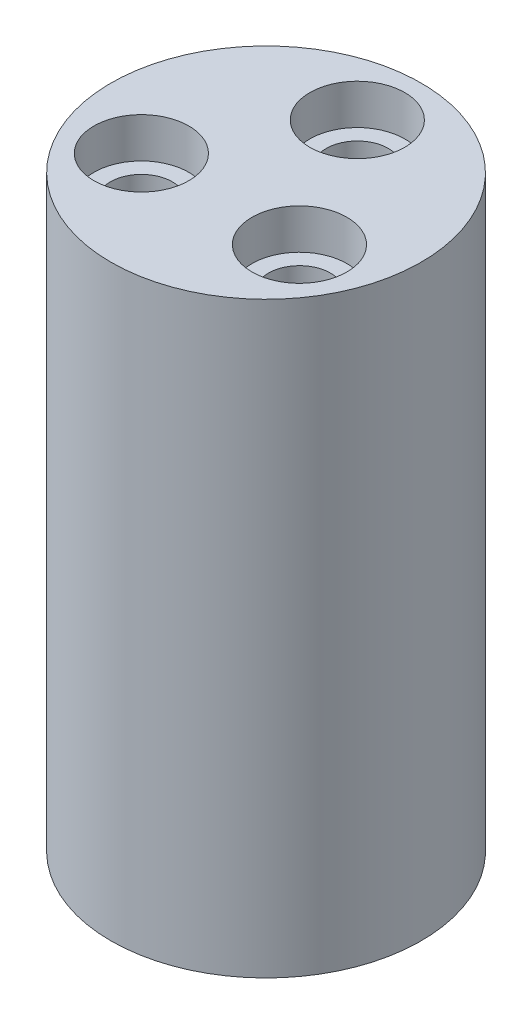
from build123d import *

# Parameters (mm, degrees)
SKETCH1_R           = 8.5
SKETCH1_R_2         = 1.7
BOSS_EXTRUDE1_DEPTH = 32.2
SKETCH2_R           = 2.6
CUT_EXTRUDE1_DEPTH  = 2.2


with BuildPart() as part:
    # Sketch1 → Boss-Extrude1 (new body)
    with BuildSketch(Plane(origin=(0, 0, 0), x_dir=(1, 0, 0), z_dir=(0, 1, 0))):
        Circle(SKETCH1_R)
        with Locations((0, 5)):
            Circle(SKETCH1_R_2, mode=Mode.SUBTRACT)
        with Locations((4.330127019, -2.5)):
            Circle(SKETCH1_R_2, mode=Mode.SUBTRACT)
        with Locations((-4.330127019, -2.5)):
            Circle(SKETCH1_R_2, mode=Mode.SUBTRACT)
    extrude(amount=BOSS_EXTRUDE1_DEPTH)

    # Sketch2 → Cut-Extrude1 (cut)
    with BuildSketch(Plane(origin=(0, 32.2, 0), x_dir=(1, 0, 0), z_dir=(0, 1, 0))):
        with Locations((0, 5)):
            Circle(SKETCH2_R)
        with Locations((4.330127019, -2.5)):
            Circle(SKETCH2_R)
        with Locations((-4.330127019, -2.5)):
            Circle(SKETCH2_R)
    extrude(amount=-CUT_EXTRUDE1_DEPTH, mode=Mode.SUBTRACT)


solid = part.part
